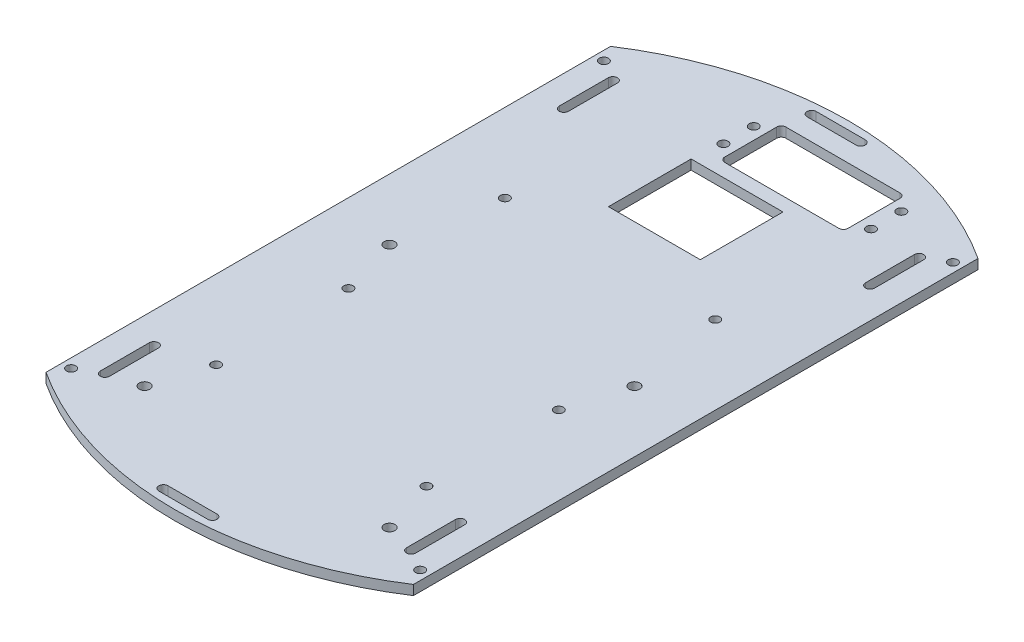
from build123d import *

# Parameters (mm, degrees)
SKETCH_1_R      = 1.5
SKETCH_1_R_2    = 1.75
SKETCH_1_W      = 30
SKETCH_1_H      = 27
EXTRUDE_1_DEPTH = 3.175


with BuildPart() as part:
    # 草图1 → 凸台-拉伸1 (new body)
    with BuildSketch(Plane(origin=(0, 0, 0), x_dir=(1, 0, 0), z_dir=(0, 1, 0))):
        with BuildLine():
            Line((-60, 29.195444573), (-60, -155.195444573))
            ThreePointArc((-60, -155.195444573), (0, -173), (60, -155.195444573))
            Line((60, -155.195444573), (60, 29.195444573))
            ThreePointArc((60, 29.195444573), (0, 47), (-60, 29.195444573))
        make_face()
        with Locations((-57, -150)):
            Circle(SKETCH_1_R, mode=Mode.SUBTRACT)
        with Locations((57, -150)):
            Circle(SKETCH_1_R, mode=Mode.SUBTRACT)
        with Locations((57, 24)):
            Circle(SKETCH_1_R, mode=Mode.SUBTRACT)
        with Locations((-57, 24)):
            Circle(SKETCH_1_R, mode=Mode.SUBTRACT)
        with Locations((-14, 29.95)):
            Circle(SKETCH_1_R, mode=Mode.SUBTRACT)
        with Locations((-14, 20.05)):
            Circle(SKETCH_1_R, mode=Mode.SUBTRACT)
        with Locations((34.2, 29.95)):
            Circle(SKETCH_1_R, mode=Mode.SUBTRACT)
        with Locations((34.2, 20.05)):
            Circle(SKETCH_1_R, mode=Mode.SUBTRACT)
        with Locations((-40, -63)):
            Circle(SKETCH_1_R_2, mode=Mode.SUBTRACT)
        with Locations((-40, -143)):
            Circle(SKETCH_1_R_2, mode=Mode.SUBTRACT)
        with Locations((40, -143)):
            Circle(SKETCH_1_R_2, mode=Mode.SUBTRACT)
        with Locations((40, -63)):
            Circle(SKETCH_1_R_2, mode=Mode.SUBTRACT)
        with Locations((-34.35, -82.074857642)):
            Circle(SKETCH_1_R, mode=Mode.SUBTRACT)
        with Locations((-34.35, -125.274857642)):
            Circle(SKETCH_1_R, mode=Mode.SUBTRACT)
        with Locations((34.35, -125.274857642)):
            Circle(SKETCH_1_R, mode=Mode.SUBTRACT)
        with Locations((34.35, -82.074857642)):
            Circle(SKETCH_1_R, mode=Mode.SUBTRACT)
        with Locations((-34.35, -30.974465683)):
            Circle(SKETCH_1_R, mode=Mode.SUBTRACT)
        with Locations((34.35, -30.974465683)):
            Circle(SKETCH_1_R, mode=Mode.SUBTRACT)
        with BuildLine():
            Line((-8.55, 35), (28.75, 35))
            ThreePointArc((28.75, 35), (29.810660172, 34.560660172), (30.25, 33.5))
            Line((30.25, 33.5), (30.25, 16.5))
            ThreePointArc((30.25, 16.5), (29.810660172, 15.439339828), (28.75, 15))
            Line((28.75, 15), (-8.55, 15))
            ThreePointArc((-8.55, 15), (-9.610660172, 15.439339828), (-10.05, 16.5))
            Line((-10.05, 16.5), (-10.05, 33.5))
            ThreePointArc((-10.05, 33.5), (-9.610660172, 34.560660172), (-8.55, 35))
        make_face(mode=Mode.SUBTRACT)
        with BuildLine():
            Line((-8, 41.359537153), (8, 41.359537153))
            ThreePointArc((8, 41.359537153), (9.5, 42.859537153), (8, 44.359537153))
            Line((8, 44.359537153), (-8, 44.359537153))
            ThreePointArc((-8, 44.359537153), (-9.5, 42.859537153), (-8, 41.359537153))
        make_face(mode=Mode.SUBTRACT)
        with BuildLine():
            Line((-8, -170.359537153), (8, -170.359537153))
            ThreePointArc((8, -170.359537153), (9.5, -168.859537153), (8, -167.359537153))
            Line((8, -167.359537153), (-8, -167.359537153))
            ThreePointArc((-8, -167.359537153), (-9.5, -168.859537153), (-8, -170.359537153))
        make_face(mode=Mode.SUBTRACT)
        with BuildLine():
            Line((-48.5, 19.95), (-48.5, 3.95))
            ThreePointArc((-48.5, 3.95), (-50, 2.45), (-51.5, 3.95))
            Line((-51.5, 3.95), (-51.5, 19.95))
            ThreePointArc((-51.5, 19.95), (-50, 21.45), (-48.5, 19.95))
        make_face(mode=Mode.SUBTRACT)
        with BuildLine():
            Line((51.5, 3.95), (51.5, 19.95))
            ThreePointArc((51.5, 19.95), (50, 21.45), (48.5, 19.95))
            Line((48.5, 19.95), (48.5, 3.95))
            ThreePointArc((48.5, 3.95), (50, 2.45), (51.5, 3.95))
        make_face(mode=Mode.SUBTRACT)
        with BuildLine():
            Line((48.5, -145.95), (48.5, -129.95))
            ThreePointArc((48.5, -129.95), (50, -128.45), (51.5, -129.95))
            Line((51.5, -129.95), (51.5, -145.95))
            ThreePointArc((51.5, -145.95), (50, -147.45), (48.5, -145.95))
        make_face(mode=Mode.SUBTRACT)
        with BuildLine():
            Line((-51.5, -129.95), (-51.5, -145.95))
            ThreePointArc((-51.5, -145.95), (-50, -147.45), (-48.5, -145.95))
            Line((-48.5, -145.95), (-48.5, -129.95))
            ThreePointArc((-48.5, -129.95), (-50, -128.45), (-51.5, -129.95))
        make_face(mode=Mode.SUBTRACT)
        with Locations((0, -3)):
            Rectangle(SKETCH_1_W, SKETCH_1_H, mode=Mode.SUBTRACT)
    extrude(amount=EXTRUDE_1_DEPTH)


solid = part.part
